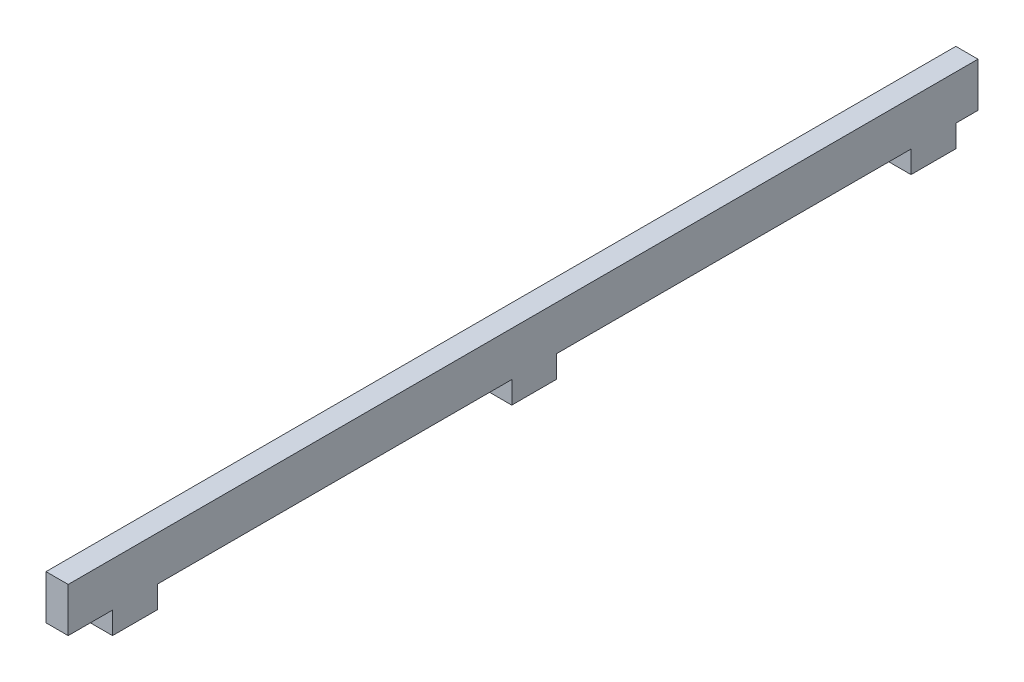
from build123d import *

# Parameters (mm, degrees)
BOSS_EXTRUDE1_DEPTH = 6.35


with BuildPart() as part:
    # Sketch1 → Boss-Extrude1 (new body)
    with BuildSketch(Plane(origin=(0, 0, 0), x_dir=(0, 0, -1), z_dir=(1, 0, 0))):
        Polygon((0, 0), (0, -12.7), (12.7, -12.7), (12.7, -19.05), (25.527, -19.05), (25.527, -12.7), (127, -12.7), (127, -19.05), (139.827, -19.05), (139.827, -12.7), (241.3, -12.7), (241.3, -19.05), (254.127, -19.05), (254.127, -12.7), (260.477, -12.7), (260.477, 0), align=None)
    extrude(amount=BOSS_EXTRUDE1_DEPTH)


solid = part.part
